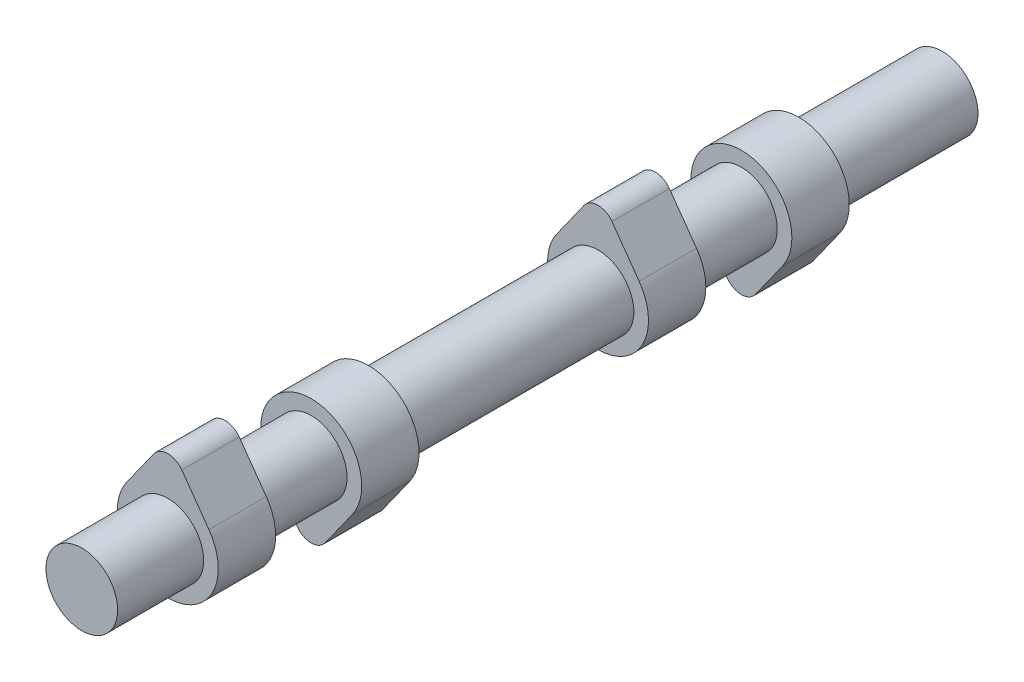
from build123d import *

# Parameters (mm, degrees)
SKETCH1_R           = 6.25
BOSS_EXTRUDE1_DEPTH = 150
SKETCH2_R           = 6.25
BOSS_EXTRUDE2_DEPTH = 10
SKETCH3_R           = 6.25
BOSS_EXTRUDE3_DEPTH = 10
BOSS_EXTRUDE4_DEPTH = 10
BOSS_EXTRUDE5_DEPTH = 10


with BuildPart() as part:
    # Sketch1 → Boss-Extrude1 (new body)
    with BuildSketch(Plane.XY):
        Circle(SKETCH1_R)
    extrude(amount=BOSS_EXTRUDE1_DEPTH)

    # Sketch2 → Boss-Extrude2 (add)
    with BuildSketch(Plane.XY.offset(135)):
        with BuildLine():
            Line((-2.443849423, 11.74), (-7.168624973, 5.104))
            ThreePointArc((-7.168624973, 5.104), (0, -8.8), (7.168624973, 5.104))
            Line((7.168624973, 5.104), (2.443849423, 11.74))
            ThreePointArc((2.443849423, 11.74), (0, 13), (-2.443849423, 11.74))
        make_face()
        Circle(SKETCH2_R, mode=Mode.SUBTRACT)
    extrude(amount=-BOSS_EXTRUDE2_DEPTH)

    # Sketch3 → Boss-Extrude3 (add)
    with BuildSketch(Plane(origin=(0, 0, 110), x_dir=(-1, 0, 0), z_dir=(0, 0, -1))):
        with BuildLine():
            Line((2.443849423, -11.74), (7.168624973, -5.104))
            ThreePointArc((7.168624973, -5.104), (0, 8.8), (-7.168624973, -5.104))
            Line((-7.168624973, -5.104), (-2.443849423, -11.74))
            ThreePointArc((-2.443849423, -11.74), (0, -13), (2.443849423, -11.74))
        make_face()
        Circle(SKETCH3_R, mode=Mode.SUBTRACT)
    extrude(amount=BOSS_EXTRUDE3_DEPTH)

    # Sketch4 → Boss-Extrude4 (add)
    with BuildSketch(Plane(origin=(0, 0, 60), x_dir=(-1, 0, 0), z_dir=(0, 0, -1))):
        with BuildLine():
            Line((-2.443849423, 11.74), (-7.168624973, 5.104))
            ThreePointArc((-7.168624973, 5.104), (0, -8.8), (7.168624973, 5.104))
            Line((7.168624973, 5.104), (2.443849423, 11.74))
            ThreePointArc((2.443849423, 11.74), (0, 13), (-2.443849423, 11.74))
        make_face()
    extrude(amount=BOSS_EXTRUDE4_DEPTH)

    # Sketch5 → Boss-Extrude5 (add)
    with BuildSketch(Plane(origin=(0, 0, 35), x_dir=(-1, 0, 0), z_dir=(0, 0, -1))):
        with BuildLine():
            Line((2.443849423, -11.74), (7.168624973, -5.104))
            ThreePointArc((7.168624973, -5.104), (0, 8.8), (-7.168624973, -5.104))
            Line((-7.168624973, -5.104), (-2.443849423, -11.74))
            ThreePointArc((-2.443849423, -11.74), (0, -13), (2.443849423, -11.74))
        make_face()
    extrude(amount=BOSS_EXTRUDE5_DEPTH)


solid = part.part
